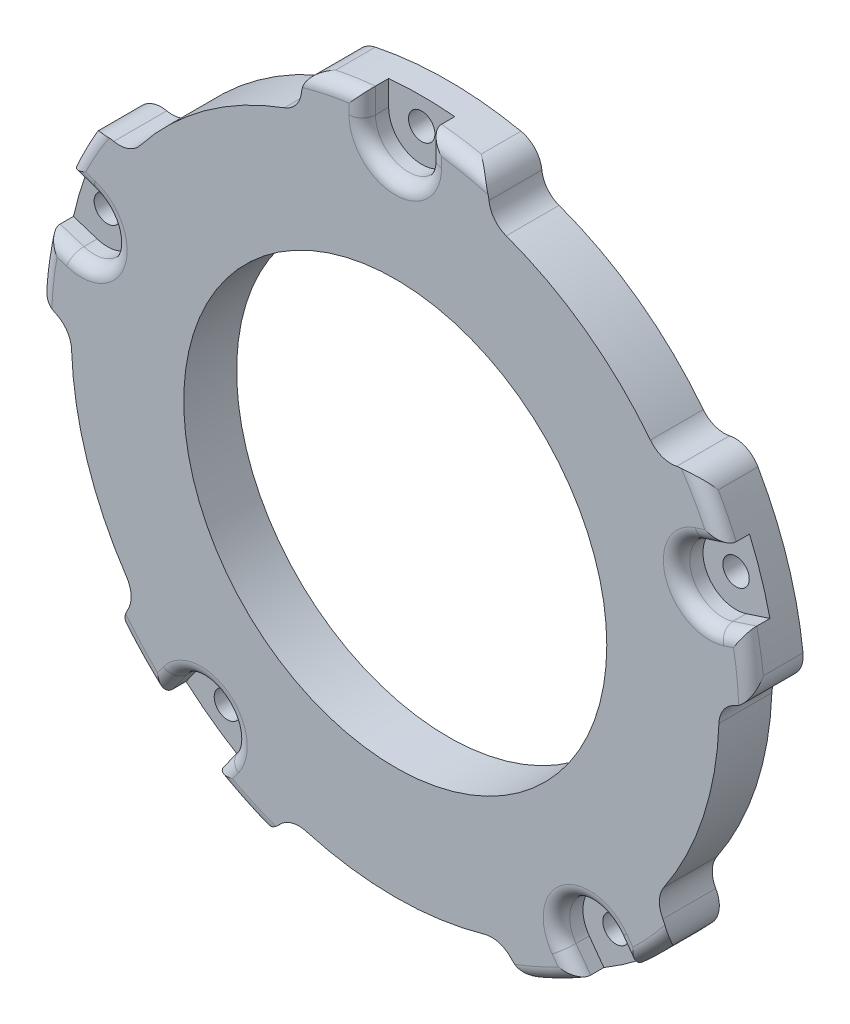
from build123d import *

# Parameters (mm, degrees)
SKETCH_1_R          = 25
SKETCH_1_R_2        = 16
SKETCH_1_R_3        = 1
EXTRUDE_1_DEPTH     = 4
SKETCH_2_R          = 27
SKETCH_2_R_2        = 25
EXTRUDE_2_DEPTH     = 4
SKETCH_3_R          = 1
EXTRUDE_3_DEPTH     = 4
SKETCH_4_R          = 1
CUT_EXTRUDE_1_DEPTH = 10
SKETCH_7_R          = 1
CUT_EXTRUDE_2_DEPTH = 2
FILLET_1_R          = 1
CUT_EXTRUDE_3_DEPTH = 12.07
FILLET_2_R          = 2


with BuildPart() as part:
    # 草图1 → 凸台-拉伸1 (new body)
    with BuildSketch(Plane.XY):
        Circle(SKETCH_1_R)
        Circle(SKETCH_1_R_2, mode=Mode.SUBTRACT)
        with Locations((21.874299875, -7.107390871)):
            Circle(SKETCH_1_R_3, mode=Mode.SUBTRACT)
        with Locations((13.519060803, -18.607390871)):
            Circle(SKETCH_1_R_3, mode=Mode.SUBTRACT)
        with Locations((0, -23)):
            Circle(SKETCH_1_R_3, mode=Mode.SUBTRACT)
        with Locations((-13.519060803, -18.607390871)):
            Circle(SKETCH_1_R_3, mode=Mode.SUBTRACT)
        with Locations((-21.874299875, -7.107390871)):
            Circle(SKETCH_1_R_3, mode=Mode.SUBTRACT)
        with Locations((-21.874299875, 7.107390871)):
            Circle(SKETCH_1_R_3, mode=Mode.SUBTRACT)
        with Locations((-13.519060803, 18.607390871)):
            Circle(SKETCH_1_R_3, mode=Mode.SUBTRACT)
        with Locations((0, 23)):
            Circle(SKETCH_1_R_3, mode=Mode.SUBTRACT)
        with Locations((13.519060803, 18.607390871)):
            Circle(SKETCH_1_R_3, mode=Mode.SUBTRACT)
        with Locations((21.874299875, 7.107390871)):
            Circle(SKETCH_1_R_3, mode=Mode.SUBTRACT)
    extrude(amount=EXTRUDE_1_DEPTH)

    # 草图2 → 凸台-拉伸2 (add)
    with BuildSketch(Plane(origin=(0, 0, 0), x_dir=(-1, 0, 0), z_dir=(0, 0, -1))):
        Circle(SKETCH_2_R)
        Circle(SKETCH_2_R_2, mode=Mode.SUBTRACT)
    extrude(amount=-EXTRUDE_2_DEPTH)

    # 草图3 → 凸台-拉伸3 (add)
    with BuildSketch(Plane(origin=(0, 0, 0), x_dir=(-1, 0, 0), z_dir=(0, 0, -1))):
        with Locations((-21.874299875, 7.107390871)):
            Circle(SKETCH_3_R)
        with Locations((-21.874299875, -7.107390871)):
            Circle(SKETCH_3_R)
        with Locations((-13.519060803, -18.607390871)):
            Circle(SKETCH_3_R)
        with Locations((0, -23)):
            Circle(SKETCH_3_R)
        with Locations((13.519060803, -18.607390871)):
            Circle(SKETCH_3_R)
        with Locations((21.874299875, -7.107390871)):
            Circle(SKETCH_3_R)
        with Locations((21.874299875, 7.107390871)):
            Circle(SKETCH_3_R)
        with Locations((0, 23)):
            Circle(SKETCH_3_R)
        with Locations((-13.519060803, 18.607390871)):
            Circle(SKETCH_3_R)
        with Locations((13.519060803, 18.607390871)):
            Circle(SKETCH_3_R)
    extrude(amount=-EXTRUDE_3_DEPTH)

    # 草图4 → 切除-拉伸1 (cut)
    with BuildSketch(Plane(origin=(0, 0, 0), x_dir=(-1, 0, 0), z_dir=(0, 0, -1))):
        with Locations((0, 25)):
            Circle(SKETCH_4_R)
        with Locations((23.776412907, 7.725424859)):
            Circle(SKETCH_4_R)
        with Locations((14.694631307, -20.225424859)):
            Circle(SKETCH_4_R)
        with Locations((-14.694631307, -20.225424859)):
            Circle(SKETCH_4_R)
        with Locations((-23.776412907, 7.725424859)):
            Circle(SKETCH_4_R)
    extrude(amount=-CUT_EXTRUDE_1_DEPTH, mode=Mode.SUBTRACT)

    # 草图7 → 切除-拉伸2 (cut)
    with BuildSketch(Plane.XY.offset(4)):
        with BuildLine():
            Line((12.672088821, -21.69488799), (13.779487352, -23.219081125))
            ThreePointArc((13.779487352, -23.219081125), (15.870201812, -21.843458848), (17.824562641, -20.280161899))
            Line((17.824562641, -20.280161899), (16.717173793, -18.755961729))
            ThreePointArc((16.717173793, -18.755961729), (13.225168177, -18.202882373), (12.672088821, -21.69488799))
        make_face()
        with Locations((14.694631307, -20.225424859)):
            Circle(SKETCH_7_R, mode=Mode.SUBTRACT)
        with BuildLine():
            ThreePointArc((-17.824562641, -20.280161899), (-15.870201812, -21.843458848), (-13.779487352, -23.219081125))
            Line((-13.779487352, -23.219081125), (-12.672088821, -21.69488799))
            ThreePointArc((-12.672088821, -21.69488799), (-13.225168177, -18.202882373), (-16.717173793, -18.755961729))
            Line((-16.717173793, -18.755961729), (-17.824562641, -20.280161899))
        make_face()
        with Locations((-14.694631307, -20.225424859)):
            Circle(SKETCH_7_R, mode=Mode.SUBTRACT)
        with BuildLine():
            Line((24.548955393, 5.347783569), (26.340754172, 5.929980576))
            ThreePointArc((26.340754172, 5.929980576), (25.67852594, 8.343458848), (24.795672899, 10.685251774))
            Line((24.795672899, 10.685251774), (23.003870421, 10.10306615))
            ThreePointArc((23.003870421, 10.10306615), (21.398771617, 6.952882373), (24.548955393, 5.347783569))
        make_face()
        with Locations((23.776412907, 7.725424859)):
            Circle(SKETCH_7_R, mode=Mode.SUBTRACT)
        with BuildLine():
            ThreePointArc((-24.795672899, 10.685251774), (-25.67852594, 8.343458848), (-26.340754172, 5.929980576))
            Line((-26.340754172, 5.929980576), (-24.548955393, 5.347783569))
            ThreePointArc((-24.548955393, 5.347783569), (-21.398771617, 6.952882373), (-23.003870421, 10.10306615))
            Line((-23.003870421, 10.10306615), (-24.795672899, 10.685251774))
        make_face()
        with Locations((-23.776412907, 7.725424859)):
            Circle(SKETCH_7_R, mode=Mode.SUBTRACT)
        with BuildLine():
            ThreePointArc((2.499994016, 26.884010674), (0, 27), (-2.499994016, 26.884010674))
            Line((-2.499994016, 26.884010674), (-2.5, 25))
            ThreePointArc((-2.5, 25), (0, 22.5), (2.5, 25))
            Line((2.5, 25), (2.499994016, 26.884010674))
        make_face()
        with Locations((0, 25)):
            Circle(SKETCH_7_R, mode=Mode.SUBTRACT)
    extrude(amount=-CUT_EXTRUDE_2_DEPTH, mode=Mode.SUBTRACT)

    # 圆角1
    fillet_1_edges = [part.edges().sort_by_distance(p)[0] for p in [
        (0, -27, 4),
        (-24.599422669, -11.129618338, 4),
        (-15.870201812, 21.843458848, 4),
        (15.870201812, 21.843458848, 4),
        (25.67852594, -8.343458848, 4),
        (-17.270868217, -19.518061814, 4),
        (-13.225788087, -22.456984558, 4),
        (-13.225168177, -18.202882373, 4),
        (25.444854783, 5.638882072, 4),
        (23.89977166, 10.394158962, 4),
        (21.398771617, 6.952882373, 4),
        (-23.89977166, 10.394158962, 4),
        (-25.444854783, 5.638882072, 4),
        (-21.398771617, 6.952882373, 4),
        (2.499997008, 25.942005337, 4),
        (-2.499997008, 25.942005337, 4),
        (0, 22.5, 4),
        (13.225788087, -22.456984558, 4),
        (17.270868217, -19.518061814, 4),
        (13.225168177, -18.202882373, 4),
    ]]
    fillet(fillet_1_edges, radius=FILLET_1_R)

    # 草图8 → 切除-拉伸3 (cut)
    with BuildSketch(Plane.XY.offset(4)):
        with BuildLine():
            ThreePointArc((-25.667849039, 0.886862845), (-25.826972173, 0.966593494), (-25.978377003, 1.060154841))
            ThreePointArc((-25.978377003, 1.060154841), (-24.727469424, -8.034441854), (-20.393805101, -16.127390164))
            ThreePointArc((-20.393805101, -16.127390164), (-20.326310001, -15.962703918), (-20.244441181, -15.804670237))
            ThreePointArc((-20.244441181, -15.804670237), (-19.97883735, -14.736230694), (-20.318912593, -13.689112134))
            ThreePointArc((-20.318912593, -13.689112134), (-23.300884649, -7.570916362), (-24.484603825, -0.86843281))
            ThreePointArc((-24.484603825, -0.86843281), (-24.824958021, 0.178595112), (-25.667849039, 0.886862845))
        make_face()
        with BuildLine():
            ThreePointArc((-9.03602715, -24.379298869), (0, -26), (9.03602715, -24.379298869))
            ThreePointArc((9.03602715, -24.379298869), (8.900258356, -24.264216365), (8.77525825, -24.137519397))
            ThreePointArc((8.77525825, -24.137519397), (7.841187958, -23.554749168), (6.740229999, -23.554602513))
            ThreePointArc((6.740229999, -23.554602513), (0, -24.5), (-6.740229999, -23.554602513))
            ThreePointArc((-6.740229999, -23.554602513), (-7.841187958, -23.554749168), (-8.77525825, -24.137519397))
            ThreePointArc((-8.77525825, -24.137519397), (-8.900258356, -24.264216365), (-9.03602715, -24.379298869))
        make_face()
        with BuildLine():
            ThreePointArc((-11.080868735, -24.621420513), (0, -27), (11.080868735, -24.621420513))
            ThreePointArc((11.080868735, -24.621420513), (10.024894314, -24.783737309), (9.03602715, -24.379298869))
            ThreePointArc((9.03602715, -24.379298869), (0, -26), (-9.03602715, -24.379298869))
            ThreePointArc((-9.03602715, -24.379298869), (-10.024894314, -24.783737309), (-11.080868735, -24.621420513))
        make_face()
        with BuildLine():
            ThreePointArc((-25.978377003, 1.060154841), (-26.668597575, 1.87564505), (-26.840539171, 2.930095053))
            ThreePointArc((-26.840539171, 2.930095053), (-25.67852594, -8.343458848), (-19.992185667, -18.146969781))
            ThreePointArc((-19.992185667, -18.146969781), (-20.472872156, -17.192837075), (-20.393805101, -16.127390164))
            ThreePointArc((-20.393805101, -16.127390164), (-24.727469424, -8.034441854), (-25.978377003, 1.060154841))
        make_face()
        with BuildLine():
            ThreePointArc((20.393805101, -16.127390164), (24.727469424, -8.034441854), (25.978377003, 1.060154841))
            ThreePointArc((25.978377003, 1.060154841), (25.826972173, 0.966593494), (25.667849039, 0.886862845))
            ThreePointArc((25.667849039, 0.886862845), (24.824958021, 0.178595112), (24.484603825, -0.86843281))
            ThreePointArc((24.484603825, -0.86843281), (23.300884649, -7.570916362), (20.318912593, -13.689112134))
            ThreePointArc((20.318912593, -13.689112134), (19.97883735, -14.736230695), (20.244441181, -15.804670237))
            ThreePointArc((20.244441181, -15.804670237), (20.326310001, -15.962703918), (20.393805101, -16.127390164))
        make_face()
        with BuildLine():
            Line((20.083521571, 14.032183056), (21.153306776, 14.336583011))
            ThreePointArc((21.153306776, 14.336583011), (21.394367837, 14.389347341), (21.640091862, 14.412023598))
            ThreePointArc((21.640091862, 14.412023598), (15.28241656, 21.034441854), (7.01949281, 25.034510594))
            ThreePointArc((7.01949281, 25.034510594), (7.061688274, 24.861603998), (7.088344874, 24.685630779))
            ThreePointArc((7.088344874, 24.685630779), (7.501479868, 23.665127017), (8.392087366, 23.01788152))
            ThreePointArc((8.392087366, 23.01788152), (14.929861697, 19.42547888), (20.083521571, 14.032183056))
        make_face()
        with BuildLine():
            ThreePointArc((7.01949281, 25.034510594), (15.28241656, 21.034441854), (21.640091862, 14.412023598))
            ThreePointArc((21.640091862, 14.412023598), (22.677825154, 14.157979633), (23.436718987, 13.405976395))
            ThreePointArc((23.436718987, 13.405976395), (15.870201812, 21.843458848), (5.507496749, 26.432318846))
            ThreePointArc((5.507496749, 26.432318846), (6.45720542, 25.942949701), (7.01949281, 25.034510594))
        make_face()
        with BuildLine():
            ThreePointArc((27, 0), (26.960105319, 1.467215456), (26.840539171, 2.930095053))
            ThreePointArc((26.840539171, 2.930095053), (26.668597575, 1.87564505), (25.978377003, 1.060154841))
            ThreePointArc((25.978377003, 1.060154841), (24.727469424, -8.034441854), (20.393805101, -16.127390164))
            ThreePointArc((20.393805101, -16.127390164), (20.472872156, -17.192837075), (19.992185667, -18.146969781))
            ThreePointArc((19.992185667, -18.146969781), (25.187189333, -9.726535534), (27, 0))
        make_face()
        with BuildLine():
            ThreePointArc((-7.088344874, 24.685630779), (-7.061688274, 24.861603998), (-7.01949281, 25.034510594))
            ThreePointArc((-7.01949281, 25.034510594), (-15.28241656, 21.034441854), (-21.640091862, 14.412023598))
            ThreePointArc((-21.640091862, 14.412023598), (-21.462608802, 14.398722791), (-21.287010983, 14.36969601))
            ThreePointArc((-21.287010983, 14.36969601), (-20.188788497, 14.447257733), (-19.298008596, 15.094265938))
            ThreePointArc((-19.298008596, 15.094265938), (-14.400738681, 19.820916362), (-8.392087366, 23.01788152))
            ThreePointArc((-8.392087366, 23.01788152), (-7.501479868, 23.665127017), (-7.088344874, 24.685630779))
        make_face()
        with BuildLine():
            ThreePointArc((-7.01949281, 25.034510594), (-6.45720542, 25.942949701), (-5.507496749, 26.432318846))
            ThreePointArc((-5.507496749, 26.432318846), (-15.870201812, 21.843458848), (-23.436718987, 13.405976395))
            ThreePointArc((-23.436718987, 13.405976395), (-22.677825154, 14.157979633), (-21.640091862, 14.412023598))
            ThreePointArc((-21.640091862, 14.412023598), (-15.28241656, 21.034441854), (-7.01949281, 25.034510594))
        make_face()
    extrude(amount=-CUT_EXTRUDE_3_DEPTH, mode=Mode.SUBTRACT)

    # 圆角2
    fillet_2_edges = [part.edges().sort_by_distance(p)[0] for p in [
        (20.083521571, 14.032183056, 2),
    ]]
    fillet(fillet_2_edges, radius=FILLET_2_R)


solid = part.part
